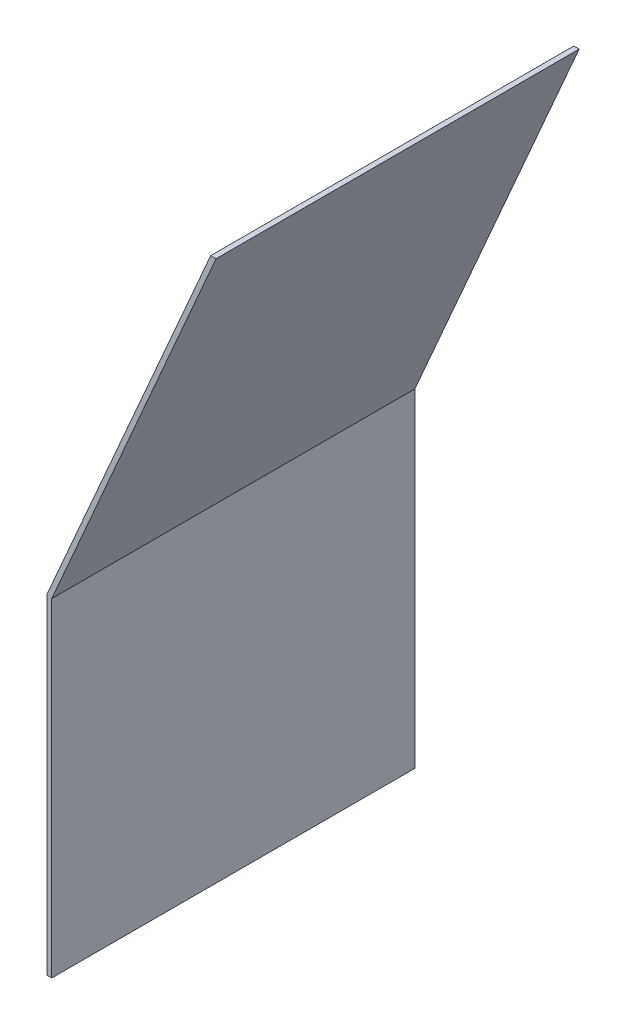
from build123d import *

# Parameters (mm, degrees)
BOSS_EXTRUDE1_DEPTH = 112.268


with BuildPart() as part:
    # Sketch1 → Boss-Extrude1 (new body)
    with BuildSketch(Plane.XY):
        Polygon((0, 0), (1.51892, 0), (1.51892, 101.6), (52.322620429, 217.995807582), (50.665319844, 217.995807582), (0, 101.917042259), align=None)
    extrude(amount=BOSS_EXTRUDE1_DEPTH)


solid = part.part
